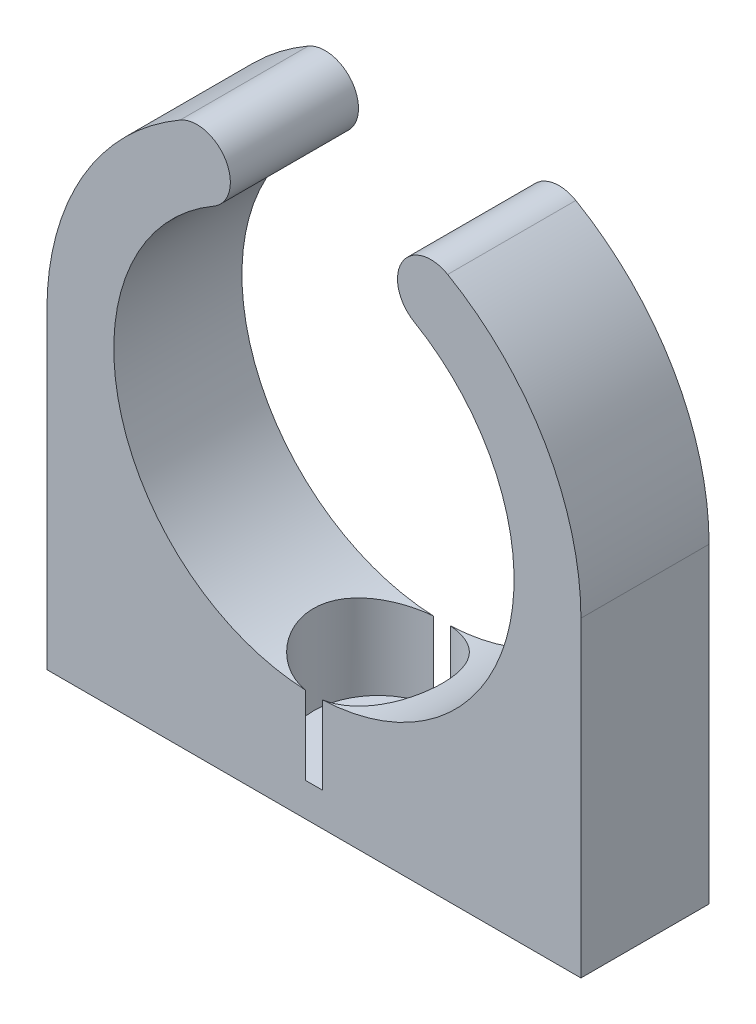
from build123d import *

# Parameters (mm, degrees)
BOSS_EXTRUDE1_DEPTH = 2.875


with BuildPart() as part:
    # Sketch1 → Boss-Extrude1 (new body, symmetric)
    with BuildSketch(Plane.XY):
        with BuildLine():
            Line((-11.98, -13.98), (11.98, -13.98))
            Line((11.98, -13.98), (11.98, 0))
            ThreePointArc((11.98, 0), (10.378283744, 5.984281622), (6.001431298, 10.368376072))
            ThreePointArc((6.001431298, 10.368376072), (3.951789306, 9.821596677), (4.498568702, 7.771954685))
            ThreePointArc((4.498568702, 7.771954685), (4.485713603, -7.779381304), (-8.98, 0))
            ThreePointArc((-8.98, 0), (-7.779381304, 4.485713603), (-4.498568702, 7.771954685))
            ThreePointArc((-4.498568702, 7.771954685), (-3.951789306, 9.821596677), (-6.001431298, 10.368376072))
            ThreePointArc((-6.001431298, 10.368376072), (-10.378283744, 5.984281622), (-11.98, 0))
            Line((-11.98, 0), (-11.98, -13.98))
        make_face()
    extrude(amount=BOSS_EXTRUDE1_DEPTH, both=True)

    # Sketch4 one side → Cut-Revolve1 (revolve, cut)
    with BuildSketch(Plane.XY):
        Polygon((-1.5, -13.98), (0, -13.98), (0, -7.48), (-2.9, -7.48), (-2.9, -12.48), (-1.5, -12.48), align=None)
    revolve(axis=Axis((0, -13.98, 0), (0, 1, 0)), mode=Mode.SUBTRACT)


solid = part.part
